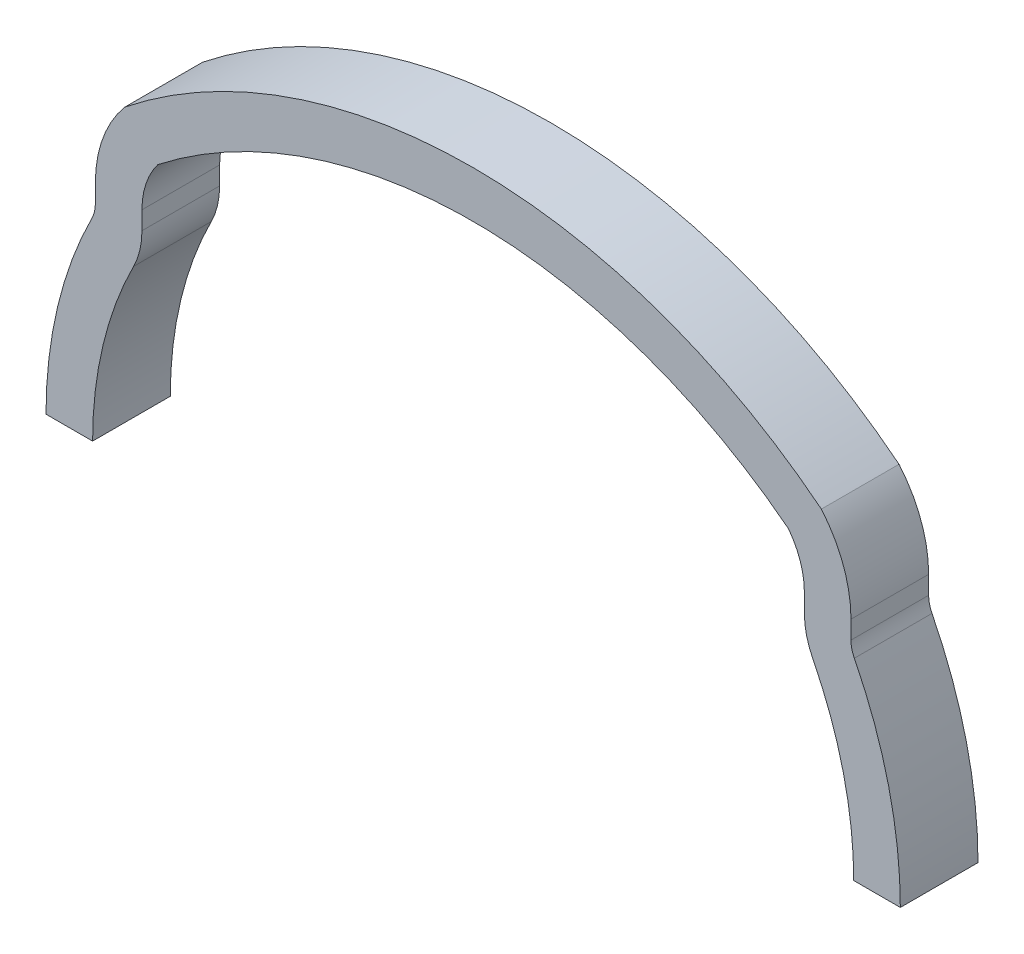
from build123d import *

# Parameters (mm, degrees)
BOSS_EXTRUDE1_DEPTH = 5


with BuildPart() as part:
    # Sketch1 → Boss-Extrude1 (new body)
    with BuildSketch(Plane.XY):
        with BuildLine():
            Line((-24.323076923, 14.485250559), (-24.323076923, 13.317117605))
            ThreePointArc((-24.323076923, 13.317117605), (-24.377668127, 12.853022124), (-24.538461538, 12.414262174))
            ThreePointArc((-24.538461538, 12.414262174), (-26.749370949, 6.381312862), (-27.5, 0))
            Line((-27.5, 0), (-24.5, 0))
            ThreePointArc((-24.5, 0), (-23.831257754, 5.685169641), (-21.861538462, 11.059979028))
            ThreePointArc((-21.861538462, 11.059979028), (-21.459554932, 12.156878903), (-21.323076923, 13.317117605))
            Line((-21.323076923, 13.317117605), (-21.323076923, 14.485250559))
            ThreePointArc((-21.323076923, 14.485250559), (-21.059553746, 16.08705807), (-20.296762002, 17.52002022))
            ThreePointArc((-20.296762002, 17.52002022), (-10.731713115, 22.70625472), (0, 24.5))
            ThreePointArc((0, 24.5), (10.731713115, 22.70625472), (20.296762002, 17.52002022))
            ThreePointArc((20.296762002, 17.52002022), (21.059553746, 16.08705807), (21.323076923, 14.485250559))
            Line((21.323076923, 14.485250559), (21.323076923, 13.317117605))
            ThreePointArc((21.323076923, 13.317117605), (21.459554932, 12.156878903), (21.861538462, 11.059979028))
            ThreePointArc((21.861538462, 11.059979028), (23.831257754, 5.685169641), (24.5, 0))
            Line((24.5, 0), (27.5, 0))
            ThreePointArc((27.5, 0), (26.749370949, 6.381312862), (24.538461538, 12.414262174))
            ThreePointArc((24.538461538, 12.414262174), (24.377668127, 12.853022124), (24.323076923, 13.317117605))
            Line((24.323076923, 13.317117605), (24.323076923, 14.485250559))
            ThreePointArc((24.323076923, 14.485250559), (23.831147361, 17.247292972), (22.41585735, 19.669652807))
            ThreePointArc((22.41585735, 19.669652807), (11.872078566, 25.486081718), (0, 27.5))
            ThreePointArc((0, 27.5), (-11.872078566, 25.486081718), (-22.41585735, 19.669652807))
            ThreePointArc((-22.41585735, 19.669652807), (-23.831147361, 17.247292972), (-24.323076923, 14.485250559))
        make_face()
    extrude(amount=BOSS_EXTRUDE1_DEPTH)


solid = part.part
